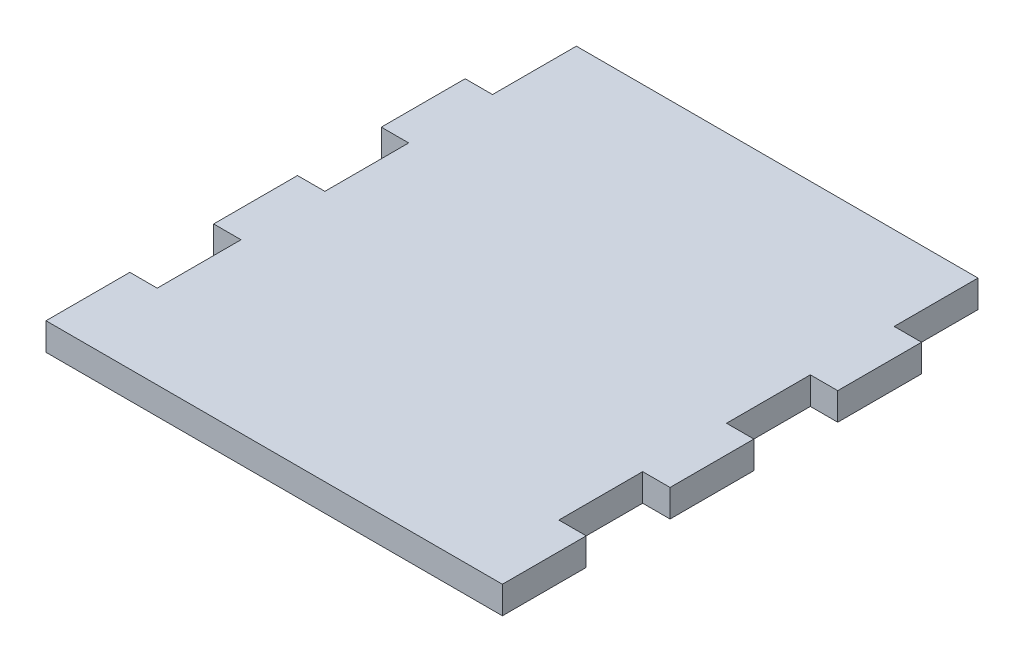
from build123d import *

# Parameters (mm, degrees)
SKETCH1_W           = 88.9
SKETCH1_H           = 114.3
BOSS_EXTRUDE1_DEPTH = 5.334
SKETCH2_W           = 5.334
SKETCH2_H           = 16.328571428
CUT_EXTRUDE1_DEPTH  = 6.334
SKETCH2_2_W         = 5.334
SKETCH2_2_H         = 16.328571428
BOSS_EXTRUDE2_DEPTH = 5.334
SKETCH2_3_W         = 5.334
SKETCH2_3_H         = 16.328571428
CUT_EXTRUDE2_DEPTH  = 6.334
CUT_EXTRUDE3_DEPTH  = 6.334


with BuildPart() as part:
    # Sketch1 → Boss-Extrude1 (new body)
    with BuildSketch(Plane(origin=(0, 0, 0), x_dir=(1, 0, 0), z_dir=(0, 1, 0))):
        Rectangle(SKETCH1_W, SKETCH1_H)
    extrude(amount=BOSS_EXTRUDE1_DEPTH)

    # Sketch2 → Cut-Extrude1 (cut, through all)
    with BuildSketch(Plane(origin=(0, 5.334, 0), x_dir=(1, 0, 0), z_dir=(0, 1, 0))):
        with Locations((41.783, -32.657142857)):
            Rectangle(SKETCH2_W, SKETCH2_H)
        with Locations((41.783, 0)):
            Rectangle(SKETCH2_W, SKETCH2_H)
        with Locations((41.783, 32.657142857)):
            Rectangle(SKETCH2_W, SKETCH2_H)
        with Locations((-41.783, 32.657142857)):
            Rectangle(SKETCH2_W, SKETCH2_H)
        with Locations((-41.783, 0)):
            Rectangle(SKETCH2_W, SKETCH2_H)
        with Locations((-41.783, -32.657142857)):
            Rectangle(SKETCH2_W, SKETCH2_H)
    extrude(amount=-CUT_EXTRUDE1_DEPTH, mode=Mode.SUBTRACT)

    # Sketch2_2 → Boss-Extrude2 (add, through all)
    with BuildSketch(Plane(origin=(0, 5.334, 0), x_dir=(1, 0, 0), z_dir=(0, 1, 0))):
        with Locations((41.783, -32.657142857)):
            Rectangle(SKETCH2_2_W, SKETCH2_2_H)
        with Locations((41.783, 0)):
            Rectangle(SKETCH2_2_W, SKETCH2_2_H)
        with Locations((41.783, 32.657142857)):
            Rectangle(SKETCH2_2_W, SKETCH2_2_H)
        with Locations((-41.783, 32.657142857)):
            Rectangle(SKETCH2_2_W, SKETCH2_2_H)
        with Locations((-41.783, 0)):
            Rectangle(SKETCH2_2_W, SKETCH2_2_H)
        with Locations((-41.783, -32.657142857)):
            Rectangle(SKETCH2_2_W, SKETCH2_2_H)
    extrude(amount=-BOSS_EXTRUDE2_DEPTH)

    # Sketch2_3 → Cut-Extrude2 (cut, through all)
    with BuildSketch(Plane(origin=(0, 5.334, 0), x_dir=(1, 0, 0), z_dir=(0, 1, 0))):
        with Locations((41.783, -32.657142857)):
            Rectangle(SKETCH2_3_W, SKETCH2_3_H)
        with Locations((41.783, 0)):
            Rectangle(SKETCH2_3_W, SKETCH2_3_H)
        with Locations((41.783, 32.657142857)):
            Rectangle(SKETCH2_3_W, SKETCH2_3_H)
        with Locations((-41.783, 32.657142857)):
            Rectangle(SKETCH2_3_W, SKETCH2_3_H)
        with Locations((-41.783, 0)):
            Rectangle(SKETCH2_3_W, SKETCH2_3_H)
        with Locations((-41.783, -32.657142857)):
            Rectangle(SKETCH2_3_W, SKETCH2_3_H)
    extrude(amount=-CUT_EXTRUDE2_DEPTH, mode=Mode.SUBTRACT)

    # Sketch3 → Cut-Extrude3 (cut, through all)
    with BuildSketch(Plane(origin=(0, 5.334, 0), x_dir=(1, 0, 0), z_dir=(0, 1, 0))):
        Polygon((44.45, 40.821428571), (-39.116, 40.821428571), (-44.45, 40.821428571), (-44.45, 57.15), (44.45, 57.15), align=None)
    extrude(amount=-CUT_EXTRUDE3_DEPTH, mode=Mode.SUBTRACT)


solid = part.part
